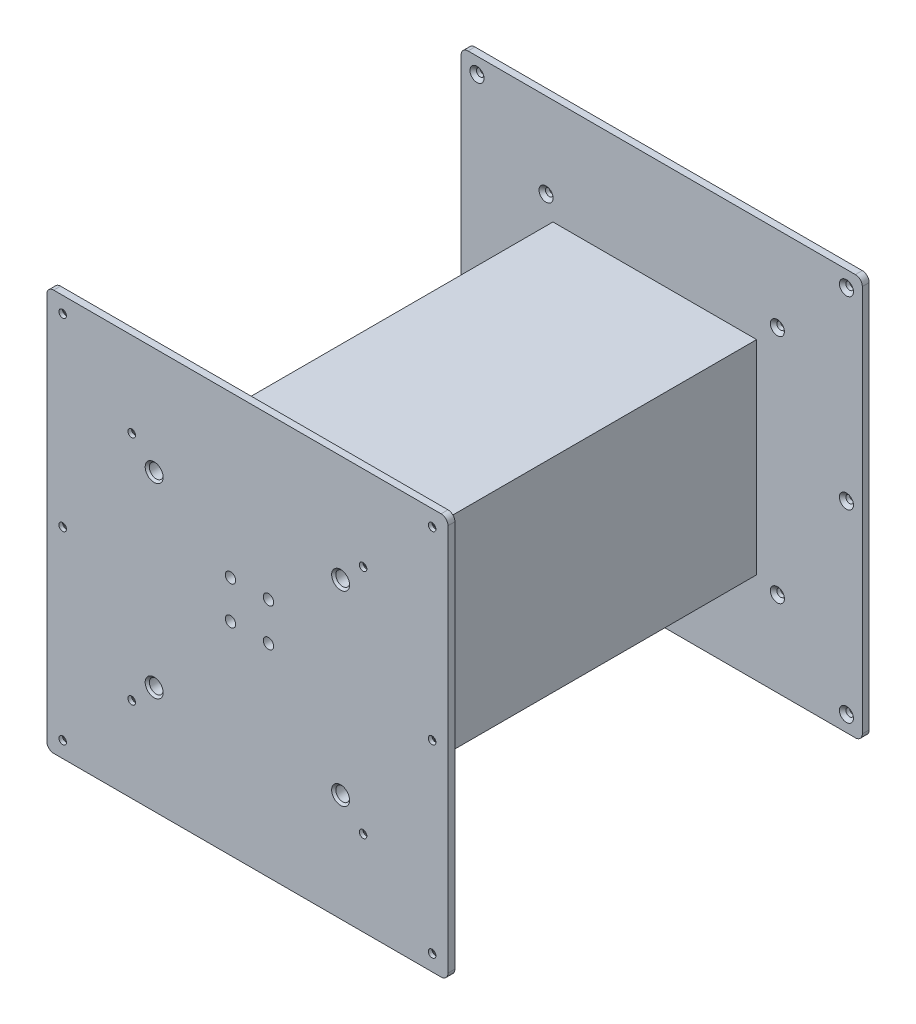
from build123d import *

# Parameters (mm, degrees)
SKETCH1_W           = 295.148
SKETCH1_H           = 295.148
BOSS_EXTRUDE1_DEPTH = 5.08
SKETCH2_W           = 139.192
SKETCH2_H           = 139.192
BOSS_EXTRUDE2_DEPTH = 5.08
SKETCH3_W           = 149.86
SKETCH3_H           = 149.86
BOSS_EXTRUDE3_DEPTH = 294.64
SKETCH4_W           = 295.148
SKETCH4_H           = 295.148
BOSS_EXTRUDE4_DEPTH = 5.08
SKETCH5_R           = 2.794
CUT_EXTRUDE1_DEPTH  = 310.88
CHAMFER1_SIZE       = 2.38
CHAMFER2_SIZE       = 2.38
FILLET1_R           = 5.08
FILLET2_R           = 5.08
SKETCH6_R           = 5.08
CUT_EXTRUDE3_DEPTH  = 35.56
CHAMFER3_SIZE       = 1.524
SKETCH7_R           = 5.08
CUT_EXTRUDE4_DEPTH  = 35.56
CHAMFER5_SIZE       = 1.524
SKETCH8_R           = 3.81
CUT_EXTRUDE5_DEPTH  = 35.56
SKETCH9_R           = 3.81
CUT_EXTRUDE6_DEPTH  = 35.56


with BuildPart() as part:
    # Sketch1 → Boss-Extrude1 (new body)
    with BuildSketch(Plane.XY):
        Rectangle(SKETCH1_W, SKETCH1_H)
    extrude(amount=BOSS_EXTRUDE1_DEPTH)

    # Sketch2 → Boss-Extrude2 (add)
    with BuildSketch(Plane.XY.offset(5.08)):
        Rectangle(SKETCH2_W, SKETCH2_H)
    extrude(amount=BOSS_EXTRUDE2_DEPTH)

    # Sketch3 → Boss-Extrude3 (add)
    with BuildSketch(Plane.XY.offset(10.16)):
        Rectangle(SKETCH3_W, SKETCH3_H)
    extrude(amount=BOSS_EXTRUDE3_DEPTH)

    # Sketch4 → Boss-Extrude4 (add)
    with BuildSketch(Plane.XY.offset(304.8)):
        Rectangle(SKETCH4_W, SKETCH4_H)
    extrude(amount=BOSS_EXTRUDE4_DEPTH)

    # Sketch5 → Cut-Extrude1 (cut, through all)
    with BuildSketch(Plane(origin=(0, 0, 0), x_dir=(-1, 0, 0), z_dir=(0, 0, -1))):
        with Locations((-135.89, 135.89)):
            Circle(SKETCH5_R)
        with Locations((135.89, 135.89)):
            Circle(SKETCH5_R)
        with Locations((135.89, -135.89)):
            Circle(SKETCH5_R)
        with Locations((-135.89, -135.89)):
            Circle(SKETCH5_R)
        with Locations((-135.89, 0)):
            Circle(SKETCH5_R)
        with Locations((135.89, 0)):
            Circle(SKETCH5_R)
        with Locations((-85.09, 85.09)):
            Circle(SKETCH5_R)
        with Locations((85.09, 85.09)):
            Circle(SKETCH5_R)
        with Locations((85.09, -85.09)):
            Circle(SKETCH5_R)
        with Locations((-85.09, -85.09)):
            Circle(SKETCH5_R)
    extrude(amount=-CUT_EXTRUDE1_DEPTH, mode=Mode.SUBTRACT)

    # Chamfer1
    chamfer1_edges = [part.edges().sort_by_distance(p)[0] for p in [
        (138.684, 135.89, 304.8),
    ]]
    chamfer(chamfer1_edges, length=CHAMFER1_SIZE)

    # Chamfer2
    chamfer2_edges = [part.edges().sort_by_distance(p)[0] for p in [
        (138.684, 135.89, 5.08),
        (-133.096, 0, 5.08),
        (-133.096, 0, 304.8),
        (87.884, 85.09, 5.08),
        (87.884, 85.09, 304.8),
        (-82.296, 85.09, 5.08),
        (-82.296, 85.09, 304.8),
        (-82.296, -85.09, 5.08),
        (-82.296, -85.09, 304.8),
        (138.684, 0, 5.08),
        (138.684, 0, 304.8),
        (138.684, -135.89, 5.08),
        (138.684, -135.89, 304.8),
        (-133.096, -135.89, 5.08),
        (-133.096, -135.89, 304.8),
        (-133.096, 135.89, 5.08),
        (-133.096, 135.89, 304.8),
        (87.884, -85.09, 5.08),
        (87.884, -85.09, 304.8),
    ]]
    chamfer(chamfer2_edges, length=CHAMFER2_SIZE)

    # Fillet1
    fillet1_edges = [part.edges().sort_by_distance(p)[0] for p in [
        (147.574, 147.574, 2.54),
    ]]
    fillet(fillet1_edges, radius=FILLET1_R)

    # Fillet2
    fillet2_edges = [part.edges().sort_by_distance(p)[0] for p in [
        (-147.574, 147.574, 307.34),
        (-147.574, -147.574, 307.34),
        (147.574, -147.574, 307.34),
        (147.574, 147.574, 307.34),
        (147.574, -147.574, 2.54),
        (-147.574, -147.574, 2.54),
        (-147.574, 147.574, 2.54),
    ]]
    fillet(fillet2_edges, radius=FILLET2_R)

    # Sketch6 → Cut-Extrude3 (cut)
    with BuildSketch(Plane.XY.offset(309.88)):
        with Locations((-68.58, -68.58)):
            Circle(SKETCH6_R)
        with Locations((-68.58, 68.58)):
            Circle(SKETCH6_R)
        with Locations((68.58, 68.58)):
            Circle(SKETCH6_R)
        with Locations((68.58, -68.58)):
            Circle(SKETCH6_R)
    extrude(amount=-CUT_EXTRUDE3_DEPTH, mode=Mode.SUBTRACT)

    # Chamfer3
    chamfer3_edges = [part.edges().sort_by_distance(p)[0] for p in [
        (63.5, -68.58, 309.88),
        (63.5, 68.58, 309.88),
        (-73.66, 68.58, 309.88),
        (-73.66, -68.58, 309.88),
    ]]
    chamfer(chamfer3_edges, length=CHAMFER3_SIZE)

    # Sketch7 → Cut-Extrude4 (cut)
    with BuildSketch(Plane(origin=(0, 0, 0), x_dir=(-1, 0, 0), z_dir=(0, 0, -1))):
        with Locations((-53.34, 53.34)):
            Circle(SKETCH7_R)
        with Locations((-53.34, -53.34)):
            Circle(SKETCH7_R)
        with Locations((53.34, -53.34)):
            Circle(SKETCH7_R)
        with Locations((53.34, 53.34)):
            Circle(SKETCH7_R)
    extrude(amount=-CUT_EXTRUDE4_DEPTH, mode=Mode.SUBTRACT)

    # Chamfer5
    chamfer5_edges = [part.edges().sort_by_distance(p)[0] for p in [
        (-48.26, 53.34, 0),
        (-48.26, -53.34, 0),
        (58.42, -53.34, 0),
        (58.42, 53.34, 0),
    ]]
    chamfer(chamfer5_edges, length=CHAMFER5_SIZE)

    # Sketch8 → Cut-Extrude5 (cut)
    with BuildSketch(Plane.XY.offset(309.88)):
        with Locations((15.494, 29.464)):
            Circle(SKETCH8_R)
        with Locations((15.494, 1.524)):
            Circle(SKETCH8_R)
        with Locations((-12.446, 1.524)):
            Circle(SKETCH8_R)
        with Locations((-12.446, 29.464)):
            Circle(SKETCH8_R)
    extrude(amount=-CUT_EXTRUDE5_DEPTH, mode=Mode.SUBTRACT)

    # Sketch9 → Cut-Extrude6 (cut)
    with BuildSketch(Plane(origin=(0, 0, 0), x_dir=(-1, 0, 0), z_dir=(0, 0, -1))):
        with Locations((15.494, 29.464)):
            Circle(SKETCH9_R)
        with Locations((15.494, 1.524)):
            Circle(SKETCH9_R)
        with Locations((-12.446, 29.464)):
            Circle(SKETCH9_R)
        with Locations((-12.446, 1.524)):
            Circle(SKETCH9_R)
    extrude(amount=-CUT_EXTRUDE6_DEPTH, mode=Mode.SUBTRACT)


solid = part.part
